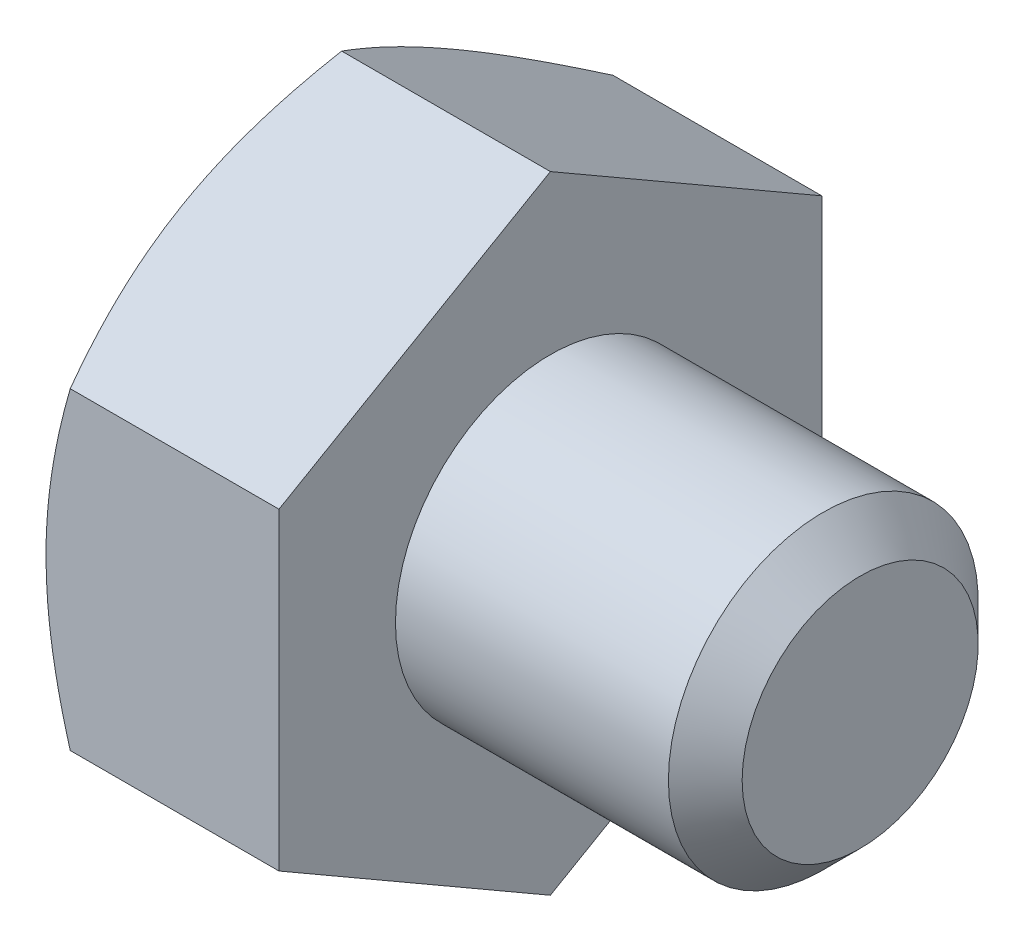
from build123d import *

# Parameters (mm, degrees)
BASEHEAD_DEPTH = 4.7752


with BuildPart() as part:
    # Sketch1 → BaseHead (new body)
    with BuildSketch(Plane(origin=(0, 0, 0), x_dir=(0, 0, -1), z_dir=(1, 0, 0))):
        Polygon((5.5626, 3.211568607), (5.5626, -3.211568607), (0, -6.423137215), (-5.5626, -3.211568607), (-5.5626, 3.211568607), (0, 6.423137215), align=None)
    extrude(amount=BASEHEAD_DEPTH)

    # BodySke → BaseBody (revolve)
    with BuildSketch(Plane.XY):
        Polygon((0, 0), (11.1252, 0), (11.1252, 2.41935), (10.36955, 3.175), (0, 3.175), align=None)
    revolve(axis=Axis((0, 0, 0), (1, 0, 0)))

    # Sketch3 → HeadChamfer (revolve, cut)
    with BuildSketch(Plane.XY):
        Polygon((0, 5.5626), (4.163005602, 12.773137215), (4.163005602, 19.123137215), (-12.7, 19.123137215), (-12.7, 5.5626), align=None)
    revolve(axis=Axis((0, 0, 0), (1, 0, 0)), mode=Mode.SUBTRACT)


solid = part.part
